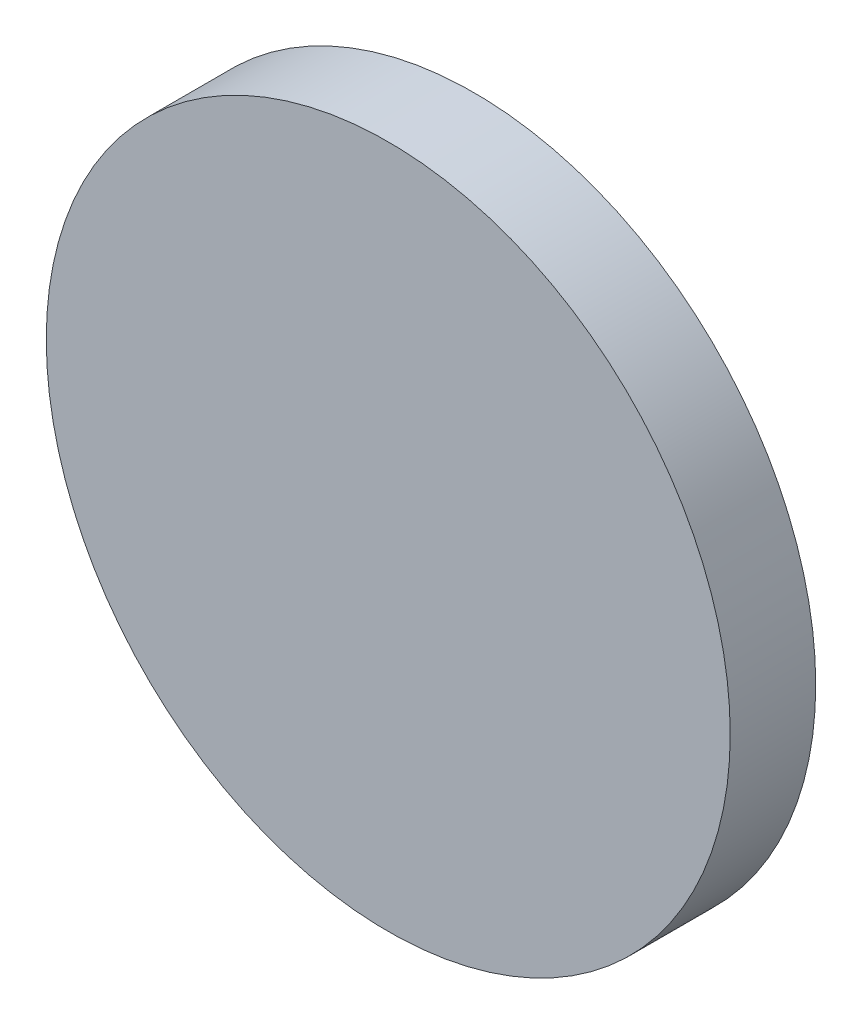
from build123d import *

# Parameters (mm, degrees)
SKETCH1_R           = 20
BOSS_EXTRUDE1_DEPTH = 5


with BuildPart() as part:
    # Sketch1 → Boss-Extrude1 (new body)
    with BuildSketch(Plane.XY):
        Circle(SKETCH1_R)
    extrude(amount=-BOSS_EXTRUDE1_DEPTH)


solid = part.part
